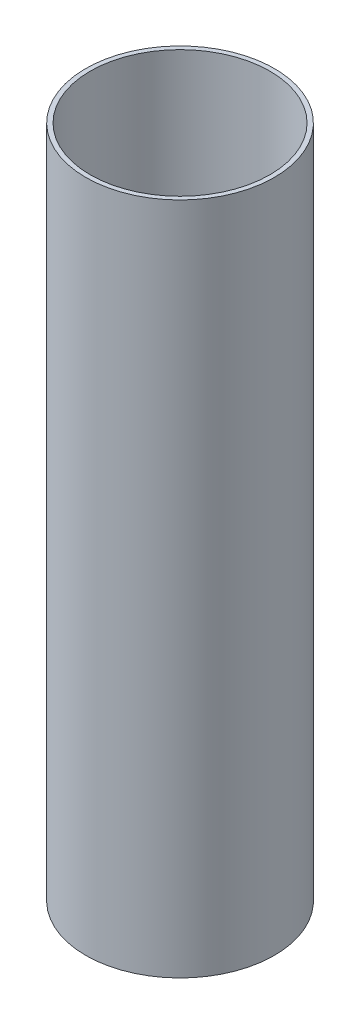
from build123d import *

# Parameters (mm, degrees)
SKETCH1_R           = 40.005
SKETCH1_R_2         = 38.1
BOSS_EXTRUDE1_DEPTH = 285.75


with BuildPart() as part:
    # Sketch1 → Boss-Extrude1 (new body)
    with BuildSketch(Plane(origin=(0, 0, 0), x_dir=(1, 0, 0), z_dir=(0, 1, 0))):
        Circle(SKETCH1_R)
        Circle(SKETCH1_R_2, mode=Mode.SUBTRACT)
    extrude(amount=BOSS_EXTRUDE1_DEPTH)


solid = part.part
